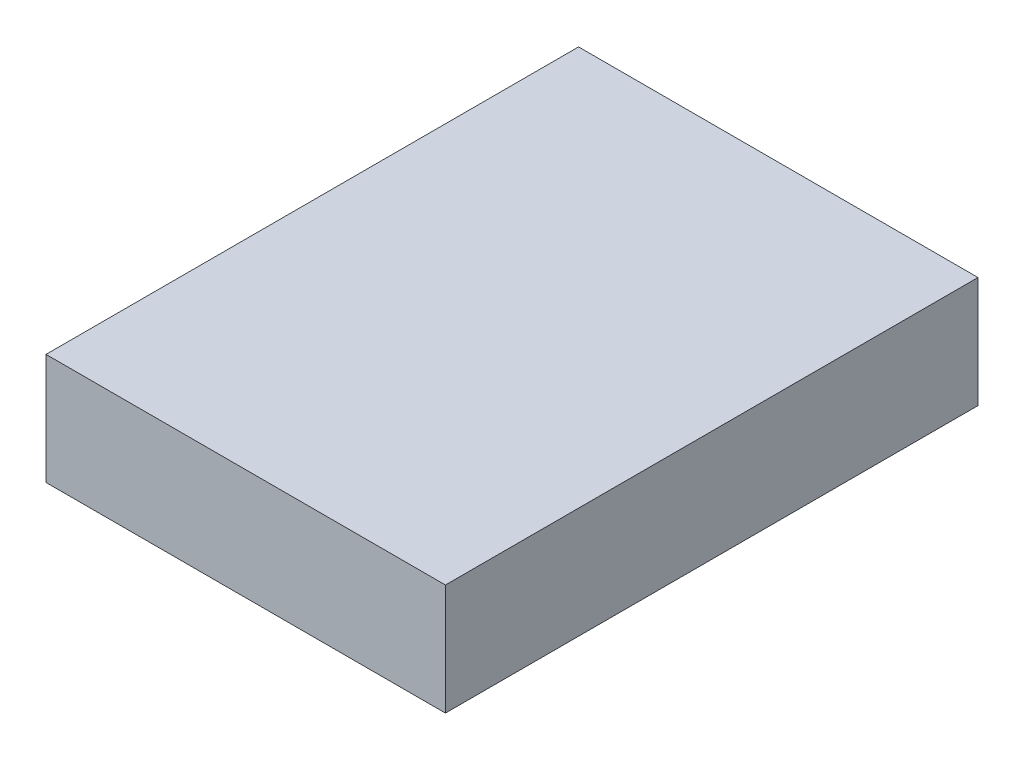
from build123d import *

# Parameters (mm, degrees)
SKETCH1_W           = 18
SKETCH1_H           = 24
BOSS_EXTRUDE1_DEPTH = 5


with BuildPart() as part:
    # Sketch1 → Boss-Extrude1 (new body)
    with BuildSketch(Plane(origin=(0, 0, 0), x_dir=(1, 0, 0), z_dir=(0, 1, 0))):
        Rectangle(SKETCH1_W, SKETCH1_H)
    extrude(amount=BOSS_EXTRUDE1_DEPTH)


solid = part.part
